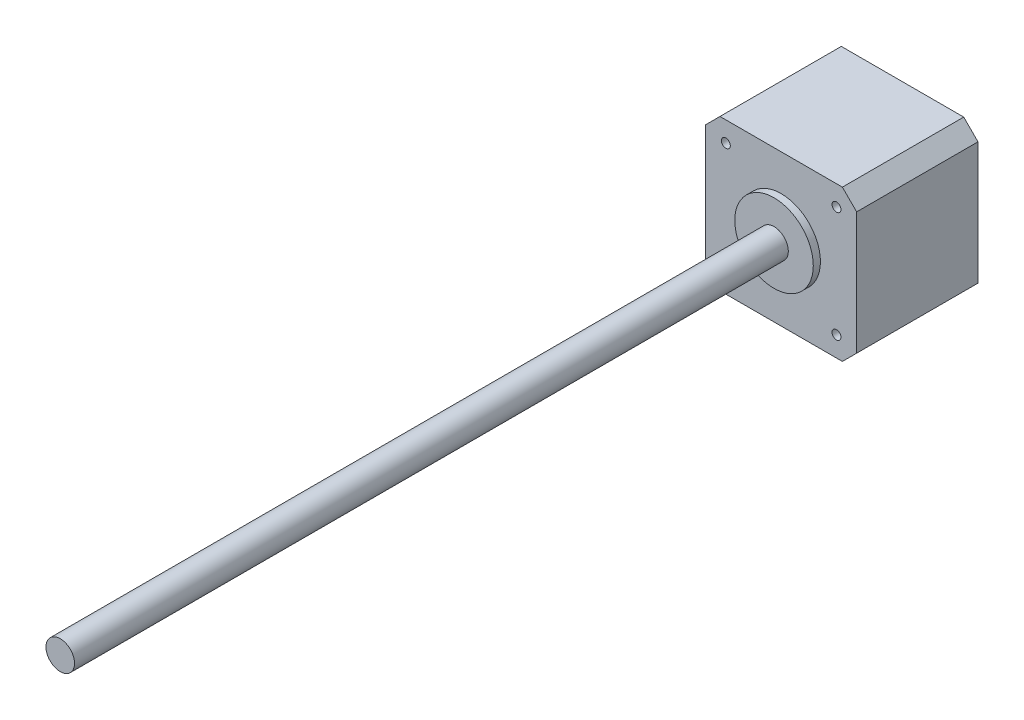
from build123d import *

# Parameters (mm, degrees)
SKETCH1_W           = 42.3
SKETCH1_H           = 42.3
BOSS_EXTRUDE1_DEPTH = 34
SKETCH2_R           = 11
BOSS_EXTRUDE2_DEPTH = 2
SKETCH3_R           = 4
BOSS_EXTRUDE3_DEPTH = 200
CHAMFER1_SIZE       = 4
SKETCH4_R           = 1.25
CUT_EXTRUDE1_DEPTH  = 10


with BuildPart() as part:
    # Sketch1 → Boss-Extrude1 (new body)
    with BuildSketch(Plane.XY):
        Rectangle(SKETCH1_W, SKETCH1_H)
    extrude(amount=BOSS_EXTRUDE1_DEPTH)

    # Sketch2 → Boss-Extrude2 (add)
    with BuildSketch(Plane.XY.offset(34)):
        Circle(SKETCH2_R)
    extrude(amount=BOSS_EXTRUDE2_DEPTH)

    # Sketch3 → Boss-Extrude3 (add)
    with BuildSketch(Plane.XY.offset(36)):
        Circle(SKETCH3_R)
    extrude(amount=BOSS_EXTRUDE3_DEPTH)

    # Chamfer1
    chamfer1_edges = [part.edges().sort_by_distance(p)[0] for p in [
        (21.15, -21.15, 17),
        (-21.15, -21.15, 17),
        (-21.15, 21.15, 17),
        (21.15, 21.15, 17),
    ]]
    chamfer(chamfer1_edges, length=CHAMFER1_SIZE)

    # Sketch4 → Cut-Extrude1 (cut)
    with BuildSketch(Plane.XY.offset(34)):
        with Locations((-15.5, 15.5)):
            Circle(SKETCH4_R)
        with Locations((15.5, 15.5)):
            Circle(SKETCH4_R)
        with Locations((15.5, -15.5)):
            Circle(SKETCH4_R)
        with Locations((-15.5, -15.5)):
            Circle(SKETCH4_R)
    extrude(amount=-CUT_EXTRUDE1_DEPTH, mode=Mode.SUBTRACT)


solid = part.part
